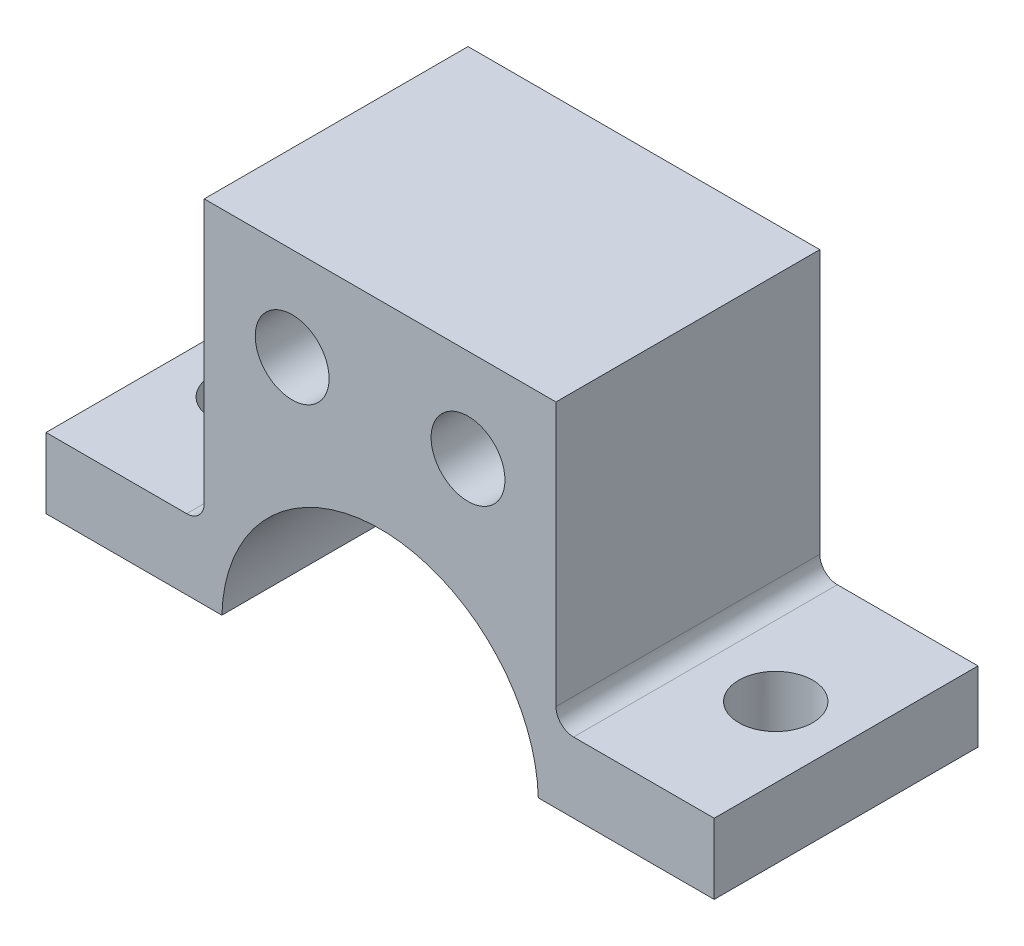
from build123d import *

# Parameters (mm, degrees)
SKETCH1_R           = 2.1
BOSS_EXTRUDE1_DEPTH = 15
SKETCH2_R           = 2.1
CUT_EXTRUDE1_DEPTH  = 10
FILLET2_R           = 1


with BuildPart() as part:
    # Sketch1 → Boss-Extrude1 (new body)
    with BuildSketch(Plane.XY):
        with BuildLine():
            ThreePointArc((18.996527108, -20), (10, -11.25), (1.003472892, -20))
            Line((1.003472892, -20), (-8.996527108, -20))
            Line((-8.996527108, -20), (-8.996527108, -16))
            Line((-8.996527108, -16), (0, -16))
            Line((0, -16), (0, 0))
            Line((0, 0), (20, 0))
            Line((20, 0), (20, -16))
            Line((20, -16), (28.996527108, -16))
            Line((28.996527108, -16), (28.996527108, -20))
            Line((28.996527108, -20), (18.996527108, -20))
        make_face()
        with Locations((15, -5.3)):
            Circle(SKETCH1_R, mode=Mode.SUBTRACT)
        with Locations((5, -5.3)):
            Circle(SKETCH1_R, mode=Mode.SUBTRACT)
    extrude(amount=BOSS_EXTRUDE1_DEPTH)

    # Sketch2 → Cut-Extrude1 (cut)
    with BuildSketch(Plane(origin=(0, -16, 0), x_dir=(1, 0, 0), z_dir=(0, 1, 0))):
        with Locations((-4.996527108, -7.5)):
            Circle(SKETCH2_R)
        with Locations((24.996527108, -7.5)):
            Circle(SKETCH2_R)
    extrude(amount=-CUT_EXTRUDE1_DEPTH, mode=Mode.SUBTRACT)

    # Fillet2
    fillet2_edges = [part.edges().sort_by_distance(p)[0] for p in [
        (0, -16, 7.5),
        (20, -16, 7.5),
    ]]
    fillet(fillet2_edges, radius=FILLET2_R)


solid = part.part
